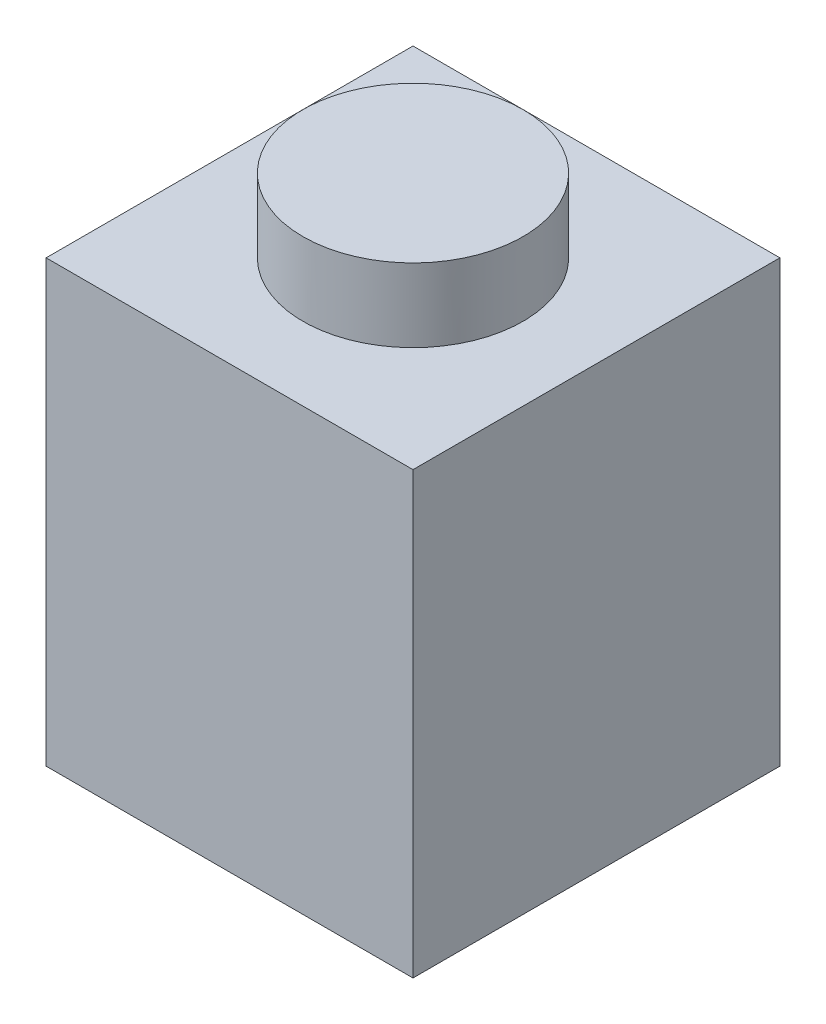
from build123d import *

# Parameters (mm, degrees)
SKETCH3_W           = 8
SKETCH3_H           = 8
BOSS_EXTRUDE1_DEPTH = 9.6
SKETCH4_R           = 2.4
BOSS_EXTRUDE2_DEPTH = 1.6
SHELL1_T            = -1.8


with BuildPart() as part:
    # Sketch3 → Boss-Extrude1 (new body)
    with BuildSketch(Plane(origin=(0, 0, 0), x_dir=(1, 0, 0), z_dir=(0, 1, 0))):
        with Locations((4, 4)):
            Rectangle(SKETCH3_W, SKETCH3_H)
    extrude(amount=BOSS_EXTRUDE1_DEPTH)

    # Sketch4 → Boss-Extrude2 (add)
    with BuildSketch(Plane(origin=(0, 9.6, 0), x_dir=(1, 0, 0), z_dir=(0, 1, 0))):
        with Locations((4, 4)):
            Circle(SKETCH4_R)
    extrude(amount=BOSS_EXTRUDE2_DEPTH)

    # Shell1
    shell1_openings = [part.faces().sort_by_distance(p)[0] for p in [
        (4, 0, -4),
    ]]
    offset(amount=SHELL1_T, openings=shell1_openings, kind=Kind.INTERSECTION)


solid = part.part
